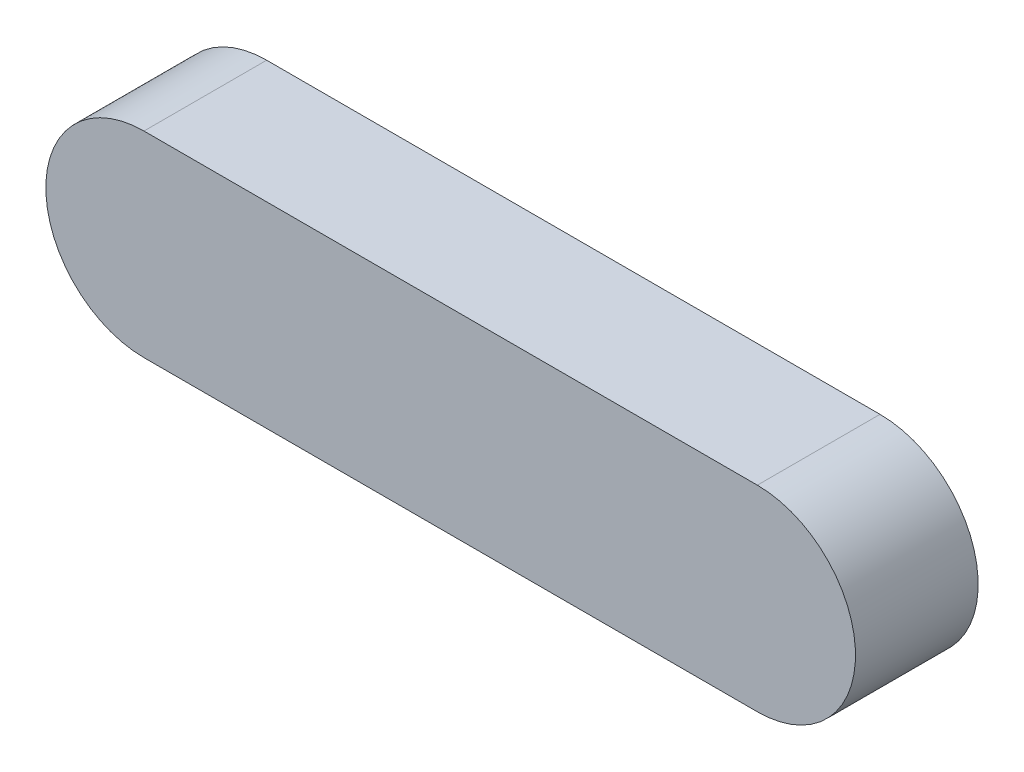
from build123d import *

# Parameters (mm, degrees)
EXTRUDE_1_DEPTH     = 50
SKETCH_1_3_R        = 30
CUT_EXTRUDE_1_DEPTH = 40


with BuildPart() as part:
    # 스케치1 → 보스-돌출1 (new body)
    with BuildSketch(Plane.XY):
        with BuildLine():
            Line((-250, -40), (0, -40))
            ThreePointArc((0, -40), (40, 0), (0, 40))
            Line((0, 40), (-250, 40))
            ThreePointArc((-250, 40), (-290, 0), (-250, -40))
        make_face()
    extrude(amount=EXTRUDE_1_DEPTH)

    # 스케치1<3> → 컷-돌출1 (cut)
    with BuildSketch(Plane.XY):
        with Locations((-250, 0)):
            Circle(SKETCH_1_3_R)
        with Locations((-187.5, 0)):
            Circle(SKETCH_1_3_R)
        with Locations((-125, 0)):
            Circle(SKETCH_1_3_R)
        with Locations((-62.5, 0)):
            Circle(SKETCH_1_3_R)
        Circle(SKETCH_1_3_R)
    extrude(amount=CUT_EXTRUDE_1_DEPTH, mode=Mode.SUBTRACT)


solid = part.part
